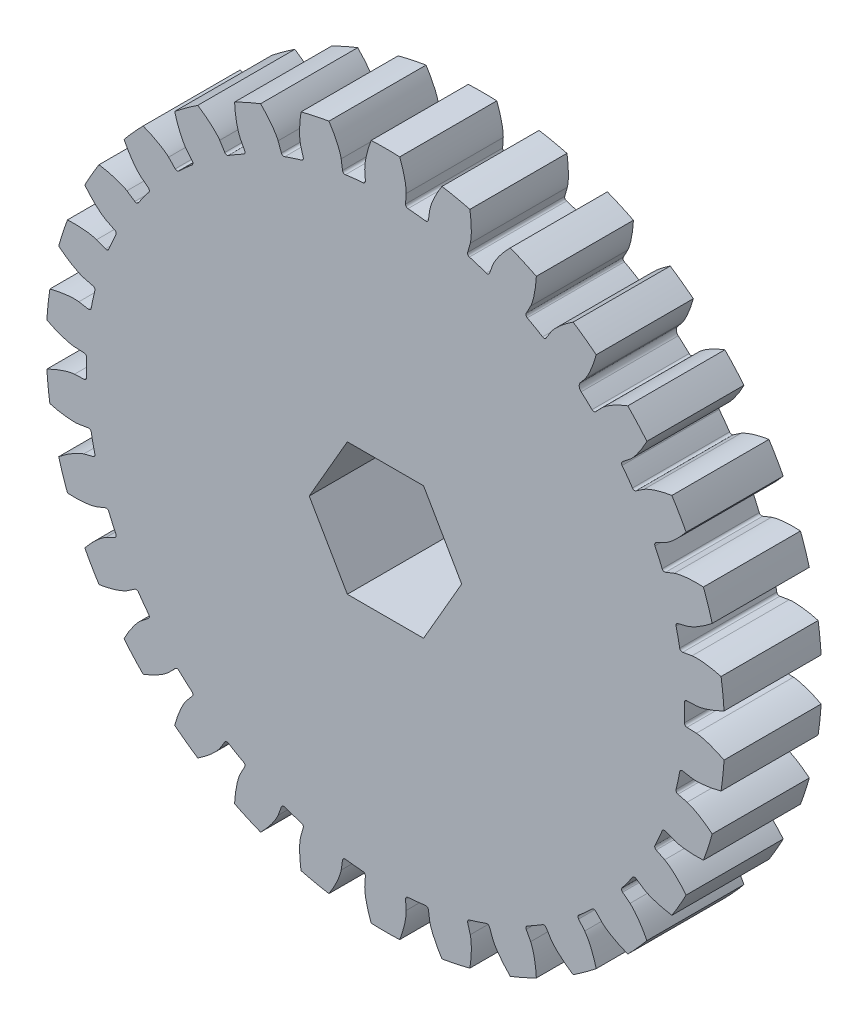
from build123d import *

# Parameters (mm, degrees)
BOSS_EXTRUDE2_DEPTH = 9.525
CUT_EXTRUDE1_DEPTH  = 10.525
CIRPATTERN1_COUNT   = 30
FILLET1_R           = 0.547580209
FILLET2_R           = 0.254
FILLET3_R           = 0.254
SKETCH2_R           = 3.175
CUT_EXTRUDE2_DEPTH  = 2.54
SKETCH3_R           = 3.175
BOSS_EXTRUDE3_DEPTH = 9.525
CUT_EXTRUDE3_DEPTH  = 10.5250001


with BuildPart() as part:
    # Sketch1 → Boss-Extrude2 (new body)
    with BuildSketch(Plane.XY):
        with BuildLine():
            add(Edge.make_bspline(
                [(30.504556384, 1.162431571), (30.508810895, 1.162632867), (30.520739326, 1.163318623), (30.543273518, 1.165093667), (30.580021714, 1.168670256), (30.62681314, 1.174227762), (30.687256986, 1.18256054), (30.758416034, 1.193856461), (30.836572221, 1.207822116), (30.921553841, 1.224692793), (31.006291597, 1.243007695), (31.090780463, 1.262660618), (31.174906545, 1.283486113), (31.276764235, 1.310189485), (31.398836319, 1.344263221), (31.541423706, 1.387088497), (31.703024125, 1.439200808), (31.867602412, 1.496109673), (32.029447998, 1.555230803), (32.192859487, 1.618566021), (32.350889825, 1.682397733), (32.514927139, 1.752402014), (32.666284825, 1.818900508), (32.835746204, 1.897514201), (32.972468272, 1.962154649), (33.113610639, 2.032366311), (33.182292562, 2.067046683), (33.21738792, 2.084984701)],
                knots=[0, 0, 0, 0, 0, 0.005376749, 0.015083688, 0.02853182, 0.04661014, 0.06485485, 0.092110526, 0.119476176, 0.146842496, 0.174208854, 0.201574956, 0.228941013, 0.256307345, 0.307035032, 0.361767352, 0.416499661, 0.471231937, 0.525964282, 0.580696616, 0.635428982, 0.690161387, 0.744893688, 0.799626082, 0.854358407, 0.909090914, 0.909090914, 0.909090914, 0.909090914, 0.909090914], degree=4))
            Line((30.504556384, 1.162431571), (29.320098742, 1.11729566))
            ThreePointArc((29.320098742, 1.11729566), (29.34137931, 0), (29.320098742, -1.11729566))
            Line((29.320098742, -1.11729566), (30.504556384, -1.162431571))
            add(Edge.make_bspline(
                [(30.504556384, -1.162431571), (30.508810895, -1.162632867), (30.520739326, -1.163318623), (30.543273518, -1.165093667), (30.580021714, -1.168670256), (30.62681314, -1.174227762), (30.687256986, -1.18256054), (30.758416034, -1.193856461), (30.836572221, -1.207822116), (30.921553841, -1.224692793), (31.006291597, -1.243007695), (31.090780463, -1.262660618), (31.174906545, -1.283486113), (31.276764235, -1.310189485), (31.398836319, -1.344263221), (31.541423706, -1.387088497), (31.703024125, -1.439200808), (31.867602412, -1.496109673), (32.029447998, -1.555230803), (32.192859487, -1.618566021), (32.350889825, -1.682397733), (32.514927139, -1.752402014), (32.666284825, -1.818900508), (32.835746204, -1.897514201), (32.972468272, -1.962154649), (33.113610639, -2.032366311), (33.182292562, -2.067046683), (33.21738792, -2.084984701)],
                knots=[0, 0, 0, 0, 0, 0.005376749, 0.015083688, 0.02853182, 0.04661014, 0.06485485, 0.092110526, 0.119476176, 0.146842496, 0.174208854, 0.201574956, 0.228941013, 0.256307345, 0.307035032, 0.361767352, 0.416499661, 0.471231937, 0.525964282, 0.580696616, 0.635428982, 0.690161387, 0.744893688, 0.799626082, 0.854358407, 0.909090914, 0.909090914, 0.909090914, 0.909090914, 0.909090914], degree=4))
            ThreePointArc((33.21738792, -2.084984701), (33.266411931, -1.043004618), (33.282758621, 0))
            ThreePointArc((33.282758621, 0), (33.266411931, 1.043004618), (33.21738792, 2.084984701))
        make_face()
        with BuildLine():
            Line((29.320098742, 1.11729566), (30.504556384, 1.162431571))
            add(Edge.make_bspline(
                [(30.504556384, 1.162431571), (30.508810895, 1.162632867), (30.520739326, 1.163318623), (30.543273518, 1.165093667), (30.580021714, 1.168670256), (30.62681314, 1.174227762), (30.687256986, 1.18256054), (30.758416034, 1.193856461), (30.836572221, 1.207822116), (30.921553841, 1.224692793), (31.006291597, 1.243007695), (31.090780463, 1.262660618), (31.174906545, 1.283486113), (31.276764235, 1.310189485), (31.398836319, 1.344263221), (31.541423706, 1.387088497), (31.703024125, 1.439200808), (31.867602412, 1.496109673), (32.029447998, 1.555230803), (32.192859487, 1.618566021), (32.350889825, 1.682397733), (32.514927139, 1.752402014), (32.666284825, 1.818900508), (32.835746204, 1.897514201), (32.972468272, 1.962154649), (33.113610639, 2.032366311), (33.182292562, 2.067046683), (33.21738792, 2.084984701)],
                knots=[0, 0, 0, 0, 0, 0.005376749, 0.015083688, 0.02853182, 0.04661014, 0.06485485, 0.092110526, 0.119476176, 0.146842496, 0.174208854, 0.201574956, 0.228941013, 0.256307345, 0.307035032, 0.361767352, 0.416499661, 0.471231937, 0.525964282, 0.580696616, 0.635428982, 0.690161387, 0.744893688, 0.799626082, 0.854358407, 0.909090914, 0.909090914, 0.909090914, 0.909090914, 0.909090914], degree=4))
            ThreePointArc((33.21738792, 2.084984701), (-33.282758621, 0), (33.21738792, -2.084984701))
            add(Edge.make_bspline(
                [(30.504556384, -1.162431571), (30.508810895, -1.162632867), (30.520739326, -1.163318623), (30.543273518, -1.165093667), (30.580021714, -1.168670256), (30.62681314, -1.174227762), (30.687256986, -1.18256054), (30.758416034, -1.193856461), (30.836572221, -1.207822116), (30.921553841, -1.224692793), (31.006291597, -1.243007695), (31.090780463, -1.262660618), (31.174906545, -1.283486113), (31.276764235, -1.310189485), (31.398836319, -1.344263221), (31.541423706, -1.387088497), (31.703024125, -1.439200808), (31.867602412, -1.496109673), (32.029447998, -1.555230803), (32.192859487, -1.618566021), (32.350889825, -1.682397733), (32.514927139, -1.752402014), (32.666284825, -1.818900508), (32.835746204, -1.897514201), (32.972468272, -1.962154649), (33.113610639, -2.032366311), (33.182292562, -2.067046683), (33.21738792, -2.084984701)],
                knots=[0, 0, 0, 0, 0, 0.005376749, 0.015083688, 0.02853182, 0.04661014, 0.06485485, 0.092110526, 0.119476176, 0.146842496, 0.174208854, 0.201574956, 0.228941013, 0.256307345, 0.307035032, 0.361767352, 0.416499661, 0.471231937, 0.525964282, 0.580696616, 0.635428982, 0.690161387, 0.744893688, 0.799626082, 0.854358407, 0.909090914, 0.909090914, 0.909090914, 0.909090914, 0.909090914], degree=4))
            Line((30.504556384, -1.162431571), (29.320098742, -1.11729566))
            ThreePointArc((29.320098742, -1.11729566), (29.34137931, 0), (29.320098742, 1.11729566))
        make_face()
        with BuildLine():
            add(Edge.make_bspline(
                [(30.504556384, 1.162431571), (30.508810895, 1.162632867), (30.520739326, 1.163318623), (30.543273518, 1.165093667), (30.580021714, 1.168670256), (30.62681314, 1.174227762), (30.687256986, 1.18256054), (30.758416034, 1.193856461), (30.836572221, 1.207822116), (30.921553841, 1.224692793), (31.006291597, 1.243007695), (31.090780463, 1.262660618), (31.174906545, 1.283486113), (31.276764235, 1.310189485), (31.398836319, 1.344263221), (31.541423706, 1.387088497), (31.703024125, 1.439200808), (31.867602412, 1.496109673), (32.029447998, 1.555230803), (32.192859487, 1.618566021), (32.350889825, 1.682397733), (32.514927139, 1.752402014), (32.666284825, 1.818900508), (32.835746204, 1.897514201), (32.972468272, 1.962154649), (33.113610639, 2.032366311), (33.182292562, 2.067046683), (33.21738792, 2.084984701)],
                knots=[0, 0, 0, 0, 0, 0.005376749, 0.015083688, 0.02853182, 0.04661014, 0.06485485, 0.092110526, 0.119476176, 0.146842496, 0.174208854, 0.201574956, 0.228941013, 0.256307345, 0.307035032, 0.361767352, 0.416499661, 0.471231937, 0.525964282, 0.580696616, 0.635428982, 0.690161387, 0.744893688, 0.799626082, 0.854358407, 0.909090914, 0.909090914, 0.909090914, 0.909090914, 0.909090914], degree=4))
            Line((30.504556384, 1.162431571), (29.320098742, 1.11729566))
            ThreePointArc((29.320098742, 1.11729566), (29.34137931, 0), (29.320098742, -1.11729566))
            Line((29.320098742, -1.11729566), (30.504556384, -1.162431571))
            add(Edge.make_bspline(
                [(30.504556384, -1.162431571), (30.508810895, -1.162632867), (30.520739326, -1.163318623), (30.543273518, -1.165093667), (30.580021714, -1.168670256), (30.62681314, -1.174227762), (30.687256986, -1.18256054), (30.758416034, -1.193856461), (30.836572221, -1.207822116), (30.921553841, -1.224692793), (31.006291597, -1.243007695), (31.090780463, -1.262660618), (31.174906545, -1.283486113), (31.276764235, -1.310189485), (31.398836319, -1.344263221), (31.541423706, -1.387088497), (31.703024125, -1.439200808), (31.867602412, -1.496109673), (32.029447998, -1.555230803), (32.192859487, -1.618566021), (32.350889825, -1.682397733), (32.514927139, -1.752402014), (32.666284825, -1.818900508), (32.835746204, -1.897514201), (32.972468272, -1.962154649), (33.113610639, -2.032366311), (33.182292562, -2.067046683), (33.21738792, -2.084984701)],
                knots=[0, 0, 0, 0, 0, 0.005376749, 0.015083688, 0.02853182, 0.04661014, 0.06485485, 0.092110526, 0.119476176, 0.146842496, 0.174208854, 0.201574956, 0.228941013, 0.256307345, 0.307035032, 0.361767352, 0.416499661, 0.471231937, 0.525964282, 0.580696616, 0.635428982, 0.690161387, 0.744893688, 0.799626082, 0.854358407, 0.909090914, 0.909090914, 0.909090914, 0.909090914, 0.909090914], degree=4))
            ThreePointArc((33.21738792, -2.084984701), (33.266411931, -1.043004618), (33.282758621, 0))
            ThreePointArc((33.282758621, 0), (33.266411931, 1.043004618), (33.21738792, 2.084984701))
        make_face()
        with BuildLine():
            Line((29.320098742, 1.11729566), (30.504556384, 1.162431571))
            add(Edge.make_bspline(
                [(30.504556384, 1.162431571), (30.508810895, 1.162632867), (30.520739326, 1.163318623), (30.543273518, 1.165093667), (30.580021714, 1.168670256), (30.62681314, 1.174227762), (30.687256986, 1.18256054), (30.758416034, 1.193856461), (30.836572221, 1.207822116), (30.921553841, 1.224692793), (31.006291597, 1.243007695), (31.090780463, 1.262660618), (31.174906545, 1.283486113), (31.276764235, 1.310189485), (31.398836319, 1.344263221), (31.541423706, 1.387088497), (31.703024125, 1.439200808), (31.867602412, 1.496109673), (32.029447998, 1.555230803), (32.192859487, 1.618566021), (32.350889825, 1.682397733), (32.514927139, 1.752402014), (32.666284825, 1.818900508), (32.835746204, 1.897514201), (32.972468272, 1.962154649), (33.113610639, 2.032366311), (33.182292562, 2.067046683), (33.21738792, 2.084984701)],
                knots=[0, 0, 0, 0, 0, 0.005376749, 0.015083688, 0.02853182, 0.04661014, 0.06485485, 0.092110526, 0.119476176, 0.146842496, 0.174208854, 0.201574956, 0.228941013, 0.256307345, 0.307035032, 0.361767352, 0.416499661, 0.471231937, 0.525964282, 0.580696616, 0.635428982, 0.690161387, 0.744893688, 0.799626082, 0.854358407, 0.909090914, 0.909090914, 0.909090914, 0.909090914, 0.909090914], degree=4))
            ThreePointArc((33.21738792, 2.084984701), (-33.282758621, 0), (33.21738792, -2.084984701))
            add(Edge.make_bspline(
                [(30.504556384, -1.162431571), (30.508810895, -1.162632867), (30.520739326, -1.163318623), (30.543273518, -1.165093667), (30.580021714, -1.168670256), (30.62681314, -1.174227762), (30.687256986, -1.18256054), (30.758416034, -1.193856461), (30.836572221, -1.207822116), (30.921553841, -1.224692793), (31.006291597, -1.243007695), (31.090780463, -1.262660618), (31.174906545, -1.283486113), (31.276764235, -1.310189485), (31.398836319, -1.344263221), (31.541423706, -1.387088497), (31.703024125, -1.439200808), (31.867602412, -1.496109673), (32.029447998, -1.555230803), (32.192859487, -1.618566021), (32.350889825, -1.682397733), (32.514927139, -1.752402014), (32.666284825, -1.818900508), (32.835746204, -1.897514201), (32.972468272, -1.962154649), (33.113610639, -2.032366311), (33.182292562, -2.067046683), (33.21738792, -2.084984701)],
                knots=[0, 0, 0, 0, 0, 0.005376749, 0.015083688, 0.02853182, 0.04661014, 0.06485485, 0.092110526, 0.119476176, 0.146842496, 0.174208854, 0.201574956, 0.228941013, 0.256307345, 0.307035032, 0.361767352, 0.416499661, 0.471231937, 0.525964282, 0.580696616, 0.635428982, 0.690161387, 0.744893688, 0.799626082, 0.854358407, 0.909090914, 0.909090914, 0.909090914, 0.909090914, 0.909090914], degree=4))
            Line((30.504556384, -1.162431571), (29.320098742, -1.11729566))
            ThreePointArc((29.320098742, -1.11729566), (29.34137931, 0), (29.320098742, 1.11729566))
        make_face()
    extrude(amount=BOSS_EXTRUDE2_DEPTH)

    # Sketch1_5 → Cut-Extrude1 (cut, through all)
    with BuildSketch(Plane.XY):
        with BuildLine():
            add(Edge.make_bspline(
                [(30.504556384, 1.162431571), (30.508810895, 1.162632867), (30.520739326, 1.163318623), (30.543273518, 1.165093667), (30.580021714, 1.168670256), (30.62681314, 1.174227762), (30.687256986, 1.18256054), (30.758416034, 1.193856461), (30.836572221, 1.207822116), (30.921553841, 1.224692793), (31.006291597, 1.243007695), (31.090780463, 1.262660618), (31.174906545, 1.283486113), (31.276764235, 1.310189485), (31.398836319, 1.344263221), (31.541423706, 1.387088497), (31.703024125, 1.439200808), (31.867602412, 1.496109673), (32.029447998, 1.555230803), (32.192859487, 1.618566021), (32.350889825, 1.682397733), (32.514927139, 1.752402014), (32.666284825, 1.818900508), (32.835746204, 1.897514201), (32.972468272, 1.962154649), (33.113610639, 2.032366311), (33.182292562, 2.067046683), (33.21738792, 2.084984701)],
                knots=[0, 0, 0, 0, 0, 0.005376749, 0.015083688, 0.02853182, 0.04661014, 0.06485485, 0.092110526, 0.119476176, 0.146842496, 0.174208854, 0.201574956, 0.228941013, 0.256307345, 0.307035032, 0.361767352, 0.416499661, 0.471231937, 0.525964282, 0.580696616, 0.635428982, 0.690161387, 0.744893688, 0.799626082, 0.854358407, 0.909090914, 0.909090914, 0.909090914, 0.909090914, 0.909090914], degree=4))
            Line((30.504556384, 1.162431571), (29.320098742, 1.11729566))
            ThreePointArc((29.320098742, 1.11729566), (29.34137931, 0), (29.320098742, -1.11729566))
            Line((29.320098742, -1.11729566), (30.504556384, -1.162431571))
            add(Edge.make_bspline(
                [(30.504556384, -1.162431571), (30.508810895, -1.162632867), (30.520739326, -1.163318623), (30.543273518, -1.165093667), (30.580021714, -1.168670256), (30.62681314, -1.174227762), (30.687256986, -1.18256054), (30.758416034, -1.193856461), (30.836572221, -1.207822116), (30.921553841, -1.224692793), (31.006291597, -1.243007695), (31.090780463, -1.262660618), (31.174906545, -1.283486113), (31.276764235, -1.310189485), (31.398836319, -1.344263221), (31.541423706, -1.387088497), (31.703024125, -1.439200808), (31.867602412, -1.496109673), (32.029447998, -1.555230803), (32.192859487, -1.618566021), (32.350889825, -1.682397733), (32.514927139, -1.752402014), (32.666284825, -1.818900508), (32.835746204, -1.897514201), (32.972468272, -1.962154649), (33.113610639, -2.032366311), (33.182292562, -2.067046683), (33.21738792, -2.084984701)],
                knots=[0, 0, 0, 0, 0, 0.005376749, 0.015083688, 0.02853182, 0.04661014, 0.06485485, 0.092110526, 0.119476176, 0.146842496, 0.174208854, 0.201574956, 0.228941013, 0.256307345, 0.307035032, 0.361767352, 0.416499661, 0.471231937, 0.525964282, 0.580696616, 0.635428982, 0.690161387, 0.744893688, 0.799626082, 0.854358407, 0.909090914, 0.909090914, 0.909090914, 0.909090914, 0.909090914], degree=4))
            ThreePointArc((33.21738792, -2.084984701), (33.266411931, -1.043004618), (33.282758621, 0))
            ThreePointArc((33.282758621, 0), (33.266411931, 1.043004618), (33.21738792, 2.084984701))
        make_face()
    cut_extrude1 = extrude(amount=CUT_EXTRUDE1_DEPTH, mode=Mode.SUBTRACT)

    # CirPattern1: Cut-Extrude1 ×30 about axis
    cirpattern1_axis = Axis((0, 0, 9.525), (0, 0, -1))
    for i in range(1, CIRPATTERN1_COUNT):
        add(cut_extrude1.rotate(cirpattern1_axis, i * 360 / CIRPATTERN1_COUNT), mode=Mode.SUBTRACT)

    # Fillet1
    fillet1_edges = [part.edges().sort_by_distance(p)[0] for p in [
        (18.788662962, 22.536696385, 4.7625),
    ]]
    fillet(fillet1_edges, radius=FILLET1_R)

    # Fillet2
    fillet2_edges = [part.edges().sort_by_distance(p)[0] for p in [
        (15.627655796, 24.833302522, 4.7625),
        (13.692442946, 25.950598182, 4.7625),
        (10.123020106, 27.53980762, 4.7625),
        (7.99779747, 28.230334314, 4.7625),
        (29.320098742, -1.11729566, 4.7625),
        (29.320098742, 1.11729566, 4.7625),
        (4.175959862, 29.042690975, 4.7625),
        (1.953609867, 29.276269372, 4.7625),
        (-1.953609867, 29.276269372, 4.7625),
        (-4.175959862, 29.042690975, 4.7625),
        (-7.99779747, 28.230334314, 4.7625),
        (-10.123020106, 27.53980762, 4.7625),
        (-13.692442946, 25.950598182, 4.7625),
        (-15.627655796, 24.833302522, 4.7625),
        (-18.788662962, 22.536696385, 4.7625),
        (-20.449287938, 21.04146294, 4.7625),
        (-23.063728248, 18.137832813, 4.7625),
        (-24.37718807, 16.33001046, 4.7625),
        (-26.330797937, 12.946258912, 4.7625),
        (-27.239688109, 10.904858162, 4.7625),
        (-28.447085408, 7.188871373, 4.7625),
        (-28.911683068, 5.003111235, 4.7625),
        (-29.320098742, 1.11729566, 4.7625),
        (-29.320098742, -1.11729566, 4.7625),
        (-28.911683068, -5.003111235, 4.7625),
        (-28.447085408, -7.188871373, 4.7625),
        (-27.239688109, -10.904858162, 4.7625),
        (-26.330797937, -12.946258912, 4.7625),
        (28.911683068, 5.003111235, 4.7625),
        (28.447085408, 7.188871373, 4.7625),
        (-24.37718807, -16.33001046, 4.7625),
        (-23.063728248, -18.137832813, 4.7625),
        (-20.449287938, -21.04146294, 4.7625),
        (-18.788662962, -22.536696385, 4.7625),
        (-15.627655796, -24.833302522, 4.7625),
        (-13.692442946, -25.950598182, 4.7625),
        (-10.123020106, -27.53980762, 4.7625),
        (-7.99779747, -28.230334314, 4.7625),
        (-4.175959862, -29.042690975, 4.7625),
        (-1.953609867, -29.276269372, 4.7625),
        (1.953609867, -29.276269372, 4.7625),
        (4.175959862, -29.042690975, 4.7625),
        (27.239688109, 10.904858162, 4.7625),
        (26.330797937, 12.946258912, 4.7625),
        (24.37718807, 16.33001046, 4.7625),
        (23.063728248, 18.137832813, 4.7625),
        (20.449287938, 21.04146294, 4.7625),
    ]]
    fillet(fillet2_edges, radius=FILLET2_R)

    # Fillet3
    fillet3_edges = [part.edges().sort_by_distance(p)[0] for p in [
        (7.99779747, -28.230334314, 4.7625),
        (10.123020106, -27.53980762, 4.7625),
        (13.692442946, -25.950598182, 4.7625),
        (15.627655796, -24.833302522, 4.7625),
        (18.788662962, -22.536696385, 4.7625),
        (20.449287938, -21.04146294, 4.7625),
        (23.063728248, -18.137832813, 4.7625),
        (24.37718807, -16.33001046, 4.7625),
        (26.330797937, -12.946258912, 4.7625),
        (27.239688109, -10.904858162, 4.7625),
        (28.447085408, -7.188871373, 4.7625),
        (28.911683068, -5.003111235, 4.7625),
    ]]
    fillet(fillet3_edges, radius=FILLET3_R)

    # Sketch2 → Cut-Extrude2 (cut)
    with BuildSketch(Plane(origin=(0, 0, 0), x_dir=(-1, 0, 0), z_dir=(0, 0, -1))):
        Circle(SKETCH2_R)
    extrude(amount=-CUT_EXTRUDE2_DEPTH, mode=Mode.SUBTRACT)

    # Sketch3 → Boss-Extrude3 (add)
    with BuildSketch(Plane(origin=(0, 0, 0), x_dir=(-1, 0, 0), z_dir=(0, 0, -1))):
        Circle(SKETCH3_R)
    extrude(amount=-BOSS_EXTRUDE3_DEPTH)

    # Sketch4 → Cut-Extrude3 (cut, through all)
    with BuildSketch(Plane(origin=(0, 0, 0), x_dir=(-1, 0, 0), z_dir=(0, 0, -1))):
        Polygon((3.739497694, 6.477), (-3.739497694, 6.477), (-7.478995387, 0), (-3.739497694, -6.477), (3.739497694, -6.477), (7.478995387, 0), align=None)
    extrude(amount=-CUT_EXTRUDE3_DEPTH, mode=Mode.SUBTRACT)


solid = part.part
